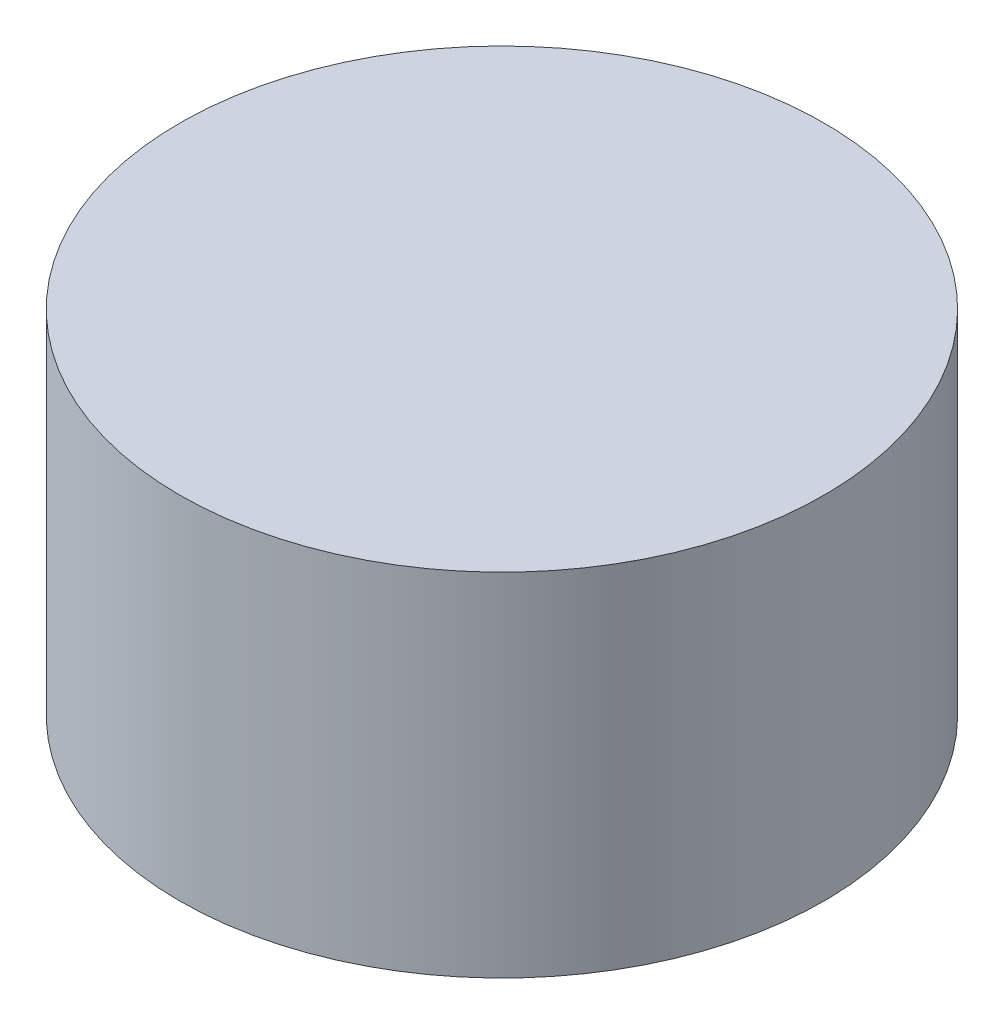
from build123d import *

# Parameters (mm, degrees)
SKETCH1_R           = 8.73125
BOSS_EXTRUDE1_DEPTH = 9.525


with BuildPart() as part:
    # Sketch1 → Boss-Extrude1 (new body)
    with BuildSketch(Plane(origin=(0, 0, 0), x_dir=(1, 0, 0), z_dir=(0, 1, 0))):
        Circle(SKETCH1_R)
    extrude(amount=BOSS_EXTRUDE1_DEPTH)


solid = part.part
